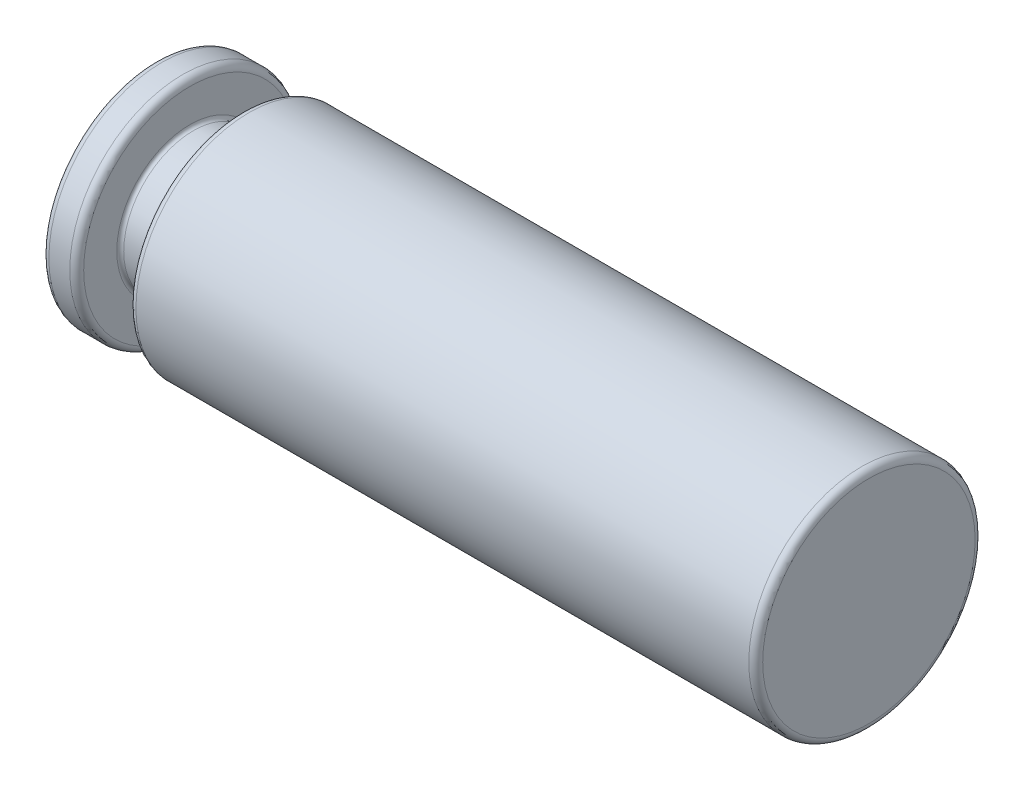
from build123d import *


with BuildPart() as part:
    # Sketch1 → Base-Revolve (revolve)
    with BuildSketch(Plane.XY):
        with BuildLine():
            Line((0, 0), (0, 12.2))
            ThreePointArc((0, 12.2), (0.234314575, 12.765685425), (0.8, 13))
            Line((0.8, 13), (3.2, 13))
            ThreePointArc((3.2, 13), (3.765685425, 12.765685425), (4, 12.2))
            Line((4, 12.2), (4, 8.4))
            ThreePointArc((4, 8.4), (4.117157288, 8.117157288), (4.4, 8))
            Line((4.4, 8), (9.6, 8))
            ThreePointArc((9.6, 8), (9.882842712, 8.117157288), (10, 8.4))
            Line((10, 8.4), (10, 12.2))
            ThreePointArc((10, 12.2), (10.234314575, 12.765685425), (10.8, 13))
            Line((10.8, 13), (81.2, 13))
            ThreePointArc((81.2, 13), (81.765685425, 12.765685425), (82, 12.2))
            Line((82, 12.2), (82, 0))
            Line((82, 0), (0, 0))
        make_face()
    revolve(axis=Axis((0, 0, 0), (1, 0, 0)))


solid = part.part
